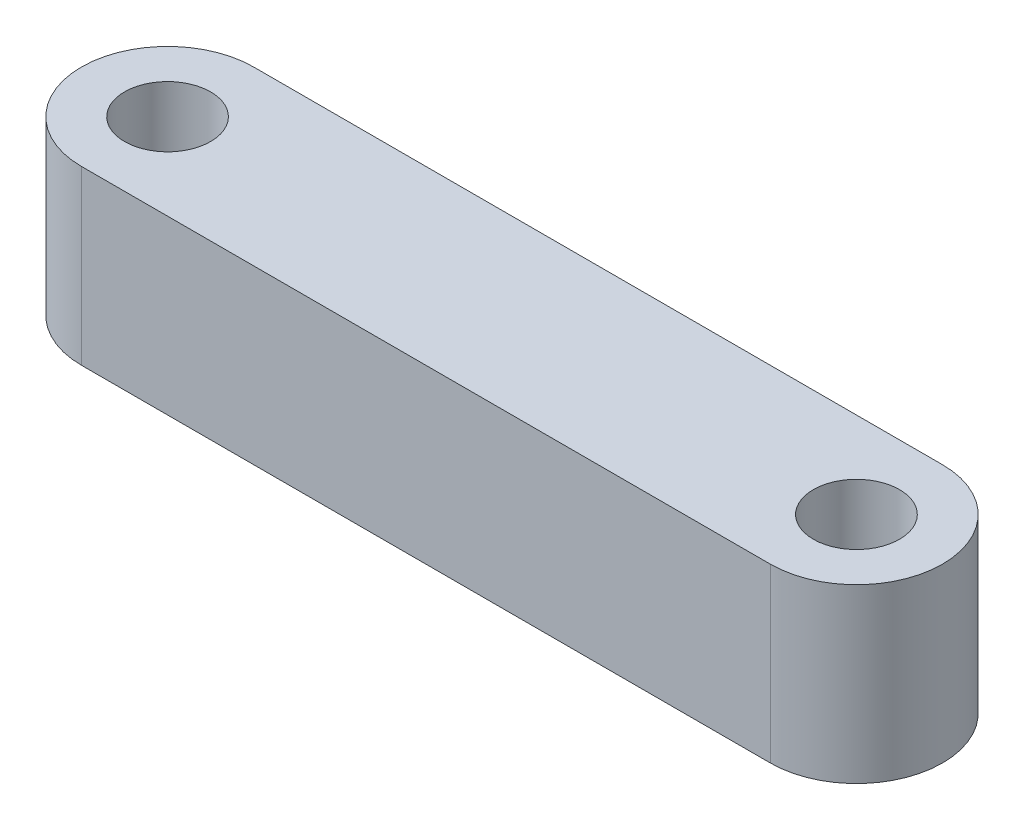
from build123d import *

# Parameters (mm, degrees)
SKETCH3_R           = 7.5
BOSS_EXTRUDE1_DEPTH = 30


with BuildPart() as part:
    # Sketch3 → Boss-Extrude1 (new body)
    with BuildSketch(Plane(origin=(0, 0, 0), x_dir=(1, 0, 0), z_dir=(0, 1, 0))):
        with BuildLine():
            ThreePointArc((120, 15), (135, 0), (120, -15))
            Line((120, -15), (0, -15))
            ThreePointArc((0, -15), (-15, 0), (0, 15))
            Line((0, 15), (120, 15))
        make_face()
        Circle(SKETCH3_R, mode=Mode.SUBTRACT)
        with Locations((120, 0)):
            Circle(SKETCH3_R, mode=Mode.SUBTRACT)
    extrude(amount=BOSS_EXTRUDE1_DEPTH)


solid = part.part
